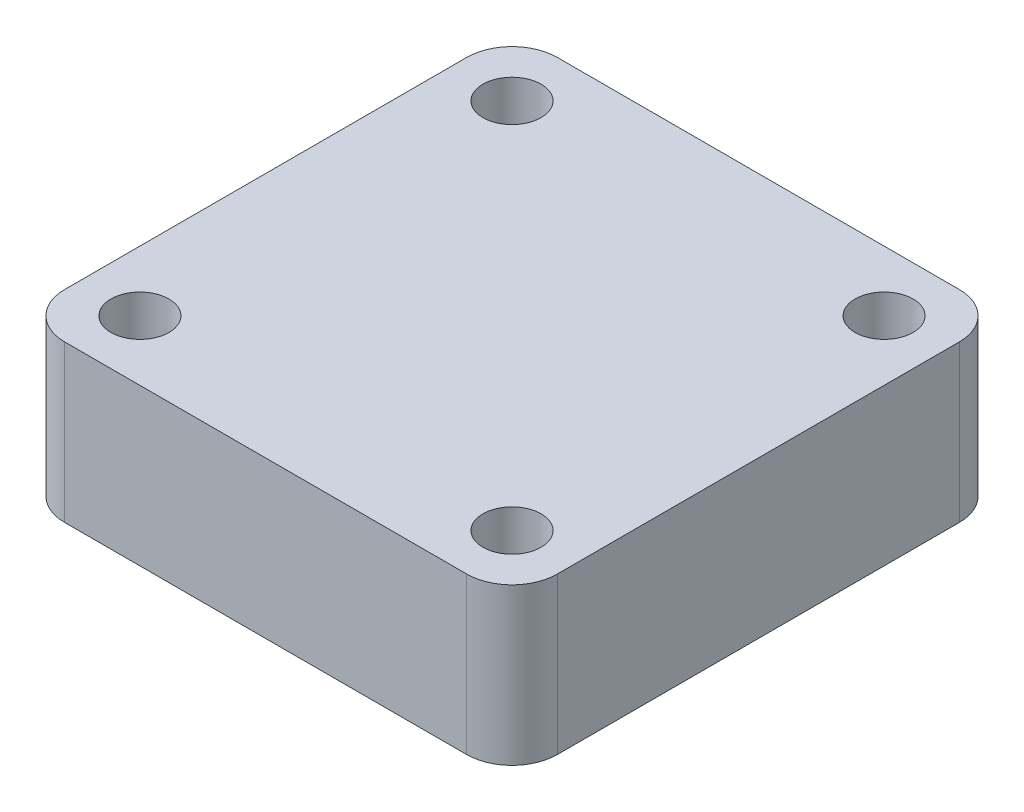
from build123d import *

# Parameters (mm, degrees)
SKETCH1_W               = 55.14
SKETCH1_H               = 55.14
BOSS_EXTRUDE1_DEPTH     = 17.5
SKETCH2_R               = 3.25
CUT_EXTRUDE1_DEPTH      = 50.8
FILLET1_R               = 5.08
SKETCH3_R               = 3.25
CUT_EXTRUDE2_DEPTH      = 1
CUT_EXTRUDE2_DEPTH_BACK = 18.5
FILLET2_R               = 5.08
SKETCH10_R              = 3.25
CUT_EXTRUDE3_DEPTH      = 1
CUT_EXTRUDE3_DEPTH_BACK = 18.5
SKETCH11_R              = 3.25
CUT_EXTRUDE4_DEPTH      = 1
CUT_EXTRUDE4_DEPTH_BACK = 18.5
FILLET3_R               = 5.08


with BuildPart() as part:
    # Sketch1 → Boss-Extrude1 (new body)
    with BuildSketch(Plane(origin=(0, 0, 0), x_dir=(1, 0, 0), z_dir=(0, 1, 0))):
        Rectangle(SKETCH1_W, SKETCH1_H)
    extrude(amount=BOSS_EXTRUDE1_DEPTH)

    # Sketch2 → Cut-Extrude1 (cut)
    with BuildSketch(Plane(origin=(0, 17.5, 0), x_dir=(1, 0, 0), z_dir=(0, 1, 0))):
        with Locations((-20.82, 20.82)):
            Circle(SKETCH2_R)
    extrude(amount=-CUT_EXTRUDE1_DEPTH, mode=Mode.SUBTRACT)

    # Fillet1
    fillet1_edges = [part.edges().sort_by_distance(p)[0] for p in [
        (-27.57, 8.75, -27.57),
    ]]
    fillet(fillet1_edges, radius=FILLET1_R)

    # Sketch3 → Cut-Extrude2 (cut, two sides)
    with BuildSketch(Plane(origin=(0, 17.5, 0), x_dir=(1, 0, 0), z_dir=(0, 1, 0))) as cut_extrude2_sk:
        with Locations((20.82, 20.82)):
            Circle(SKETCH3_R)
    extrude(amount=CUT_EXTRUDE2_DEPTH, mode=Mode.SUBTRACT)
    extrude(cut_extrude2_sk.sketch, amount=-CUT_EXTRUDE2_DEPTH_BACK, mode=Mode.SUBTRACT)

    # Fillet2
    fillet2_edges = [part.edges().sort_by_distance(p)[0] for p in [
        (27.57, 8.75, -27.57),
    ]]
    fillet(fillet2_edges, radius=FILLET2_R)

    # Sketch10 → Cut-Extrude3 (cut, two sides)
    with BuildSketch(Plane(origin=(0, 17.5, 0), x_dir=(1, 0, 0), z_dir=(0, 1, 0))) as cut_extrude3_sk:
        with Locations((-20.82, -20.82)):
            Circle(SKETCH10_R)
    extrude(amount=CUT_EXTRUDE3_DEPTH, mode=Mode.SUBTRACT)
    extrude(cut_extrude3_sk.sketch, amount=-CUT_EXTRUDE3_DEPTH_BACK, mode=Mode.SUBTRACT)

    # Sketch11 → Cut-Extrude4 (cut, two sides)
    with BuildSketch(Plane(origin=(0, 17.5, 0), x_dir=(1, 0, 0), z_dir=(0, 1, 0))) as cut_extrude4_sk:
        with Locations((20.82, -20.82)):
            Circle(SKETCH11_R)
    extrude(amount=CUT_EXTRUDE4_DEPTH, mode=Mode.SUBTRACT)
    extrude(cut_extrude4_sk.sketch, amount=-CUT_EXTRUDE4_DEPTH_BACK, mode=Mode.SUBTRACT)

    # Fillet3
    fillet3_edges = [part.edges().sort_by_distance(p)[0] for p in [
        (27.57, 8.75, 27.57),
        (-27.57, 8.75, 27.57),
    ]]
    fillet(fillet3_edges, radius=FILLET3_R)


solid = part.part
